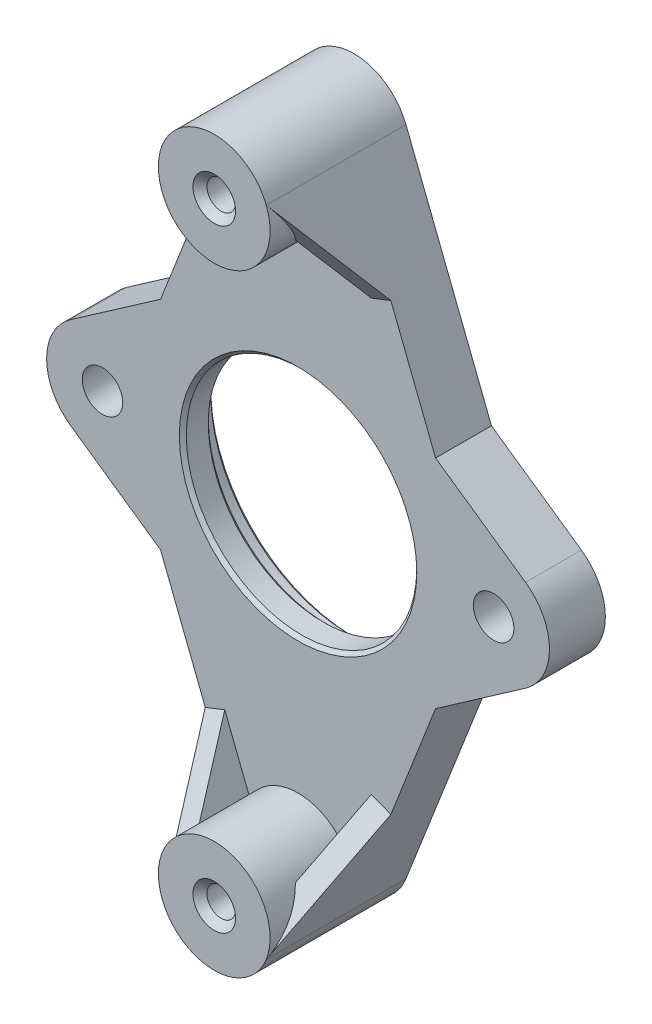
from build123d import *

# Parameters (mm, degrees)
BOSS_EXTRUDE1_DEPTH            = 4
CUT_EXTRUDE1_DEPTH             = 5
CUT_EXTRUDE1_DEPTH_BACK        = 1
SKETCH1_6_R                    = 10
CUT_EXTRUDE2_DEPTH             = 1.93
CUT_EXTRUDE2_DEPTH_BACK        = 1
M2_5_CLEARANCE_HOLE1_D         = 2.9
CHAMFER1_SIZE                  = 0.25
BOSS_EXTRUDE5_DEPTH            = 4
SKETCH4_5_R                    = 4
BOSS_EXTRUDE6_DEPTH            = 10
TAP_DRILL_FOR_M2_5X0_45_TAP2_D = 2.05
BOSS_EXTRUDE7_DEPTH            = 1.5
MIRROR4_COPY_1_DEPTH           = 1.5
CHAMFER3_SIZE                  = 0.5


with BuildPart() as part:
    # Sketch1 → Boss-Extrude1 (new body)
    with BuildSketch(Plane.XY):
        with BuildLine():
            ThreePointArc((16.285714286, -3.282607227), (18, 0), (16.285714286, 3.282607227))
            Line((16.285714286, 3.282607227), (6.857142857, 9.84782168))
            ThreePointArc((6.857142857, 9.84782168), (0, 12), (-6.857142857, 9.84782168))
            Line((-6.857142857, 9.84782168), (-16.285714286, 3.282607227))
            ThreePointArc((-16.285714286, 3.282607227), (-18, 0), (-16.285714286, -3.282607227))
            Line((-16.285714286, -3.282607227), (-6.857142857, -9.84782168))
            ThreePointArc((-6.857142857, -9.84782168), (0, -12), (6.857142857, -9.84782168))
            Line((6.857142857, -9.84782168), (16.285714286, -3.282607227))
        make_face()
    extrude(amount=BOSS_EXTRUDE1_DEPTH)

    # Sketch1_4 → Cut-Extrude1 (cut, two sides)
    with BuildSketch(Plane.XY) as cut_extrude1_sk:
        with BuildLine():
            ThreePointArc((-8.25, 0), (0, -8.25), (8.25, 0))
            Line((8.25, 0), (-8.25, 0))
        make_face()
        with BuildLine():
            Line((-8.25, 0), (8.25, 0))
            ThreePointArc((8.25, 0), (0, 8.25), (-8.25, 0))
        make_face()
    extrude(amount=CUT_EXTRUDE1_DEPTH, mode=Mode.SUBTRACT)
    extrude(cut_extrude1_sk.sketch, amount=-CUT_EXTRUDE1_DEPTH_BACK, mode=Mode.SUBTRACT)

    # Sketch1_6 → Cut-Extrude2 (cut, two sides)
    with BuildSketch(Plane.XY) as cut_extrude2_sk:
        Circle(SKETCH1_6_R)
    extrude(amount=CUT_EXTRUDE2_DEPTH, mode=Mode.SUBTRACT)
    extrude(cut_extrude2_sk.sketch, amount=-CUT_EXTRUDE2_DEPTH_BACK, mode=Mode.SUBTRACT)

    # M2.5 Clearance Hole1 (through all)
    with Locations(Plane.XY.offset(4)):
        with Locations((-14, 0), (14, 0)):
            Hole(M2_5_CLEARANCE_HOLE1_D / 2)

    # Chamfer1
    chamfer1_edges = [part.edges().sort_by_distance(p)[0] for p in [
        (-8.25, 0, 4),
        (-10, 0, 0),
        (-10, 0, 1.93),
        (-8.25, 0, 1.93),
    ]]
    chamfer(chamfer1_edges, length=CHAMFER1_SIZE)

    # Sketch4_4 → Boss-Extrude5 (add)
    with BuildSketch(Plane.XY):
        with BuildLine():
            Line((11.172261915, 4.379562044), (3.724087305, 23.379854015))
            ThreePointArc((3.724087305, 23.379854015), (0, 25.92), (-3.724087305, 23.379854015))
            Line((-3.724087305, 23.379854015), (-11.172261915, 4.379562044))
            ThreePointArc((-11.172261915, 4.379562044), (0, 12), (11.172261915, 4.379562044))
        make_face()
        with BuildLine():
            ThreePointArc((11.172261915, -4.379562044), (0, -12), (-11.172261915, -4.379562044))
            Line((-11.172261915, -4.379562044), (-3.724087305, -23.379854015))
            ThreePointArc((-3.724087305, -23.379854015), (0, -25.92), (3.724087305, -23.379854015))
            Line((3.724087305, -23.379854015), (11.172261915, -4.379562044))
        make_face()
    extrude(amount=BOSS_EXTRUDE5_DEPTH)

    # Sketch4_5 → Boss-Extrude6 (add)
    with BuildSketch(Plane.XY):
        with Locations((0, 21.92)):
            Circle(SKETCH4_5_R)
        with Locations((0, -21.92)):
            Circle(SKETCH4_5_R)
    extrude(amount=BOSS_EXTRUDE6_DEPTH)

    # Tap Drill for M2.5x0.45 Tap2 (through all)
    with Locations(Plane.XY.offset(10)):
        with Locations((0, 21.92), (0, -21.92)):
            Hole(TAP_DRILL_FOR_M2_5X0_45_TAP2_D / 2)

    # Sketch10 → Boss-Extrude7 (add)
    with BuildSketch(Plane(origin=(-11.172261915, -4.379562044, 0), x_dir=(0, 0, 1), z_dir=(-0.931021826, -0.364963504, 0))):
        Polygon((10, -20.407998432), (4, -12.407998432), (4, -20.407998432), align=None)
    boss_extrude7 = extrude(amount=-BOSS_EXTRUDE7_DEPTH)

    # Mirror3: Boss-Extrude7 across plane
    add(boss_extrude7.mirror(Plane(origin=(0, 0, 0), x_dir=(0, 0, 1), z_dir=(1, 0, 0))))

    # Mirror4: Boss-Extrude7 across plane
    add(boss_extrude7.mirror(Plane.ZX))

    # Mirror4 copy 1 sketch → Mirror4 copy 1 (add)
    with BuildSketch(Plane(origin=(11.172261915, 4.379562044, 0), x_dir=(0, 0, 1), z_dir=(0.931021826, 0.364963504, 0))):
        Polygon((10, -20.407998432), (4, -12.407998432), (4, -20.407998432), align=None)
    extrude(amount=-MIRROR4_COPY_1_DEPTH)

    # Chamfer3
    chamfer3_edges = [part.edges().sort_by_distance(p)[0] for p in [
        (1.025, -21.92, 10),
        (1.025, 21.92, 10),
    ]]
    chamfer(chamfer3_edges, length=CHAMFER3_SIZE)


solid = part.part
